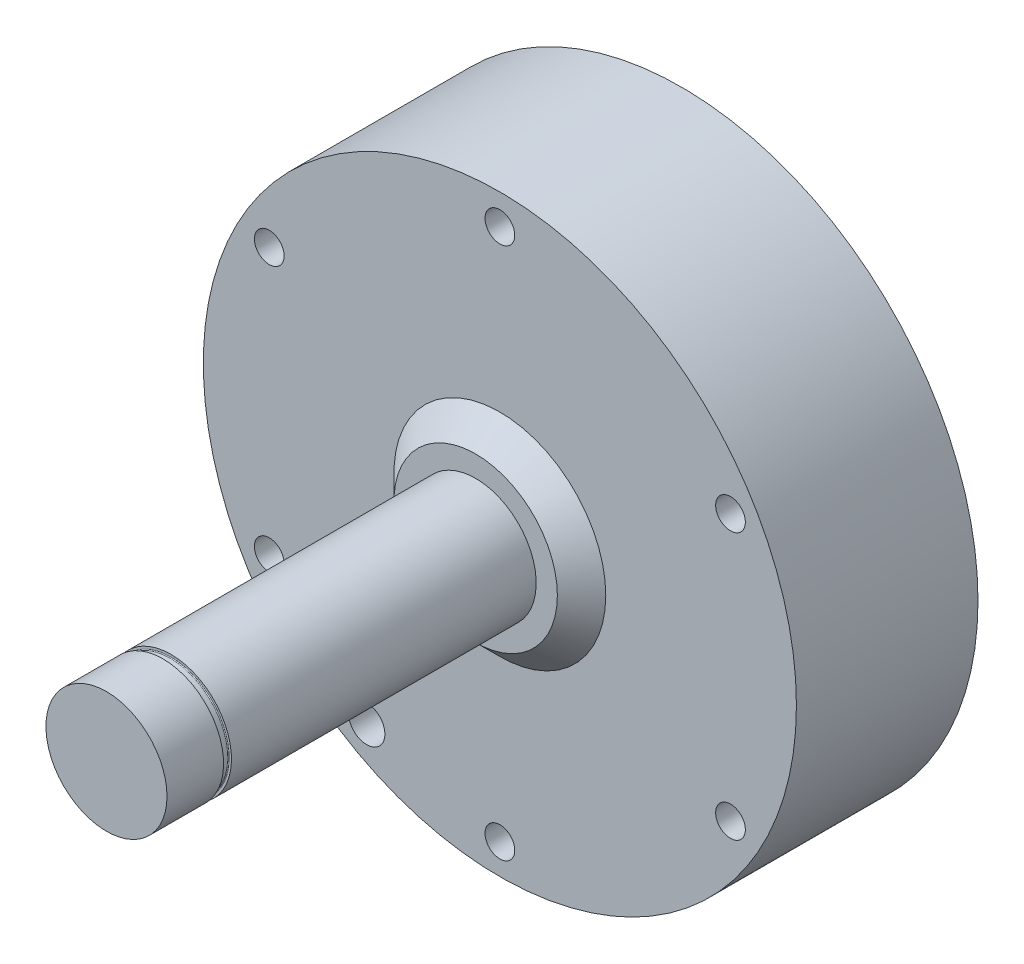
from build123d import *

# Parameters (mm, degrees)
ESQUISSE1_R                  = 49
BASE_EXTRUSION_DEPTH         = 30
ESQUISSE20_R                 = 3
ENL_V_MAT_EXTRU_4_DEPTH      = 12
ESQUISSE3_R                  = 10
BOSS_EXTRU_1_DEPTH           = 61
ESQUISSE11_R                 = 3
ENL_V_MAT_EXTRU_3_DEPTH      = 31.0000001
R_P_TITION_CIRCULAIRE1_COUNT = 6
R_P_TITION_CIRCULAIRE3_COUNT = 2
R_P_TITION_CIRCULAIRE3_ANGLE = 135
R_P_TITION_CIRCULAIRE4_COUNT = 3


with BuildPart() as part:
    # Esquisse1 → Base-Extrusion (new body)
    with BuildSketch(Plane.XY):
        Circle(ESQUISSE1_R)
    extrude(amount=BASE_EXTRUSION_DEPTH)

    # Esquisse2 → Boss.-Révol.1 (revolve)
    with BuildSketch(Plane(origin=(0, 0, 0), x_dir=(0, 0, -1), z_dir=(1, 0, 0))):
        Polygon((-30, 0), (-30, 17.5), (-34, 13.5), (-34, 0), align=None)
    revolve(axis=Axis((0, 0, 38.858858859), (0, 0, -1)))

    # Esquisse20 → Enlèv. mat.-Extru.4 (cut)
    with BuildSketch(Plane(origin=(-49, 0, 15), x_dir=(0, 1, 0), z_dir=(-1, 0, 0))):
        with Locations((0, -3)):
            Circle(ESQUISSE20_R)
    extrude(amount=-ENL_V_MAT_EXTRU_4_DEPTH, mode=Mode.SUBTRACT)

    # Esquisse3 → Boss.-Extru.1 (add)
    with BuildSketch(Plane.XY.offset(34)):
        Circle(ESQUISSE3_R)
    extrude(amount=BOSS_EXTRU_1_DEPTH)

    # Esquisse11 → Enlèv. mat.-Extru.3 (cut, through all)
    with BuildSketch(Plane.XY.offset(30)):
        with Locations((-22, -38.105117767)):
            Circle(ESQUISSE11_R)
    extrude(amount=-ENL_V_MAT_EXTRU_3_DEPTH, mode=Mode.SUBTRACT)

    # Esquisse12 → Perçage2 (revolve, cut)
    with BuildSketch(Plane(origin=(0, -44, 30), x_dir=(0, -1, 0), z_dir=(1, 0, 0))):
        Polygon((0, 0), (0, 26.47511282), (2.455, 25), (2.455, 0), align=None)
    per_age2 = revolve(axis=Axis((0, -44, 34.244199587), (0, 0, -1)), mode=Mode.SUBTRACT)

    # Répétition circulaire1: Perçage2 ×6 about axis
    r_p_tition_circulaire1_axis = Axis((0, 0, 0), (0, 0, 1))
    for i in range(1, R_P_TITION_CIRCULAIRE1_COUNT):
        add(per_age2.rotate(r_p_tition_circulaire1_axis, i * 360 / R_P_TITION_CIRCULAIRE1_COUNT), mode=Mode.SUBTRACT)

    # Esquisse16 → Perçage4 (revolve, cut)
    with BuildSketch(Plane(origin=(-21.242014496, 21.184353192, 0), x_dir=(0, 1, 0), z_dir=(1, 0, 0))):
        Polygon((0, 0), (0, 21.802581857), (3, 20), (3, 0), align=None)
    per_age4 = revolve(axis=Axis((-21.242014496, 21.184353192, -6.35), (0, 0, 1)), mode=Mode.SUBTRACT)

    # Répétition circulaire3: Perçage4 ×2 about axis
    r_p_tition_circulaire3_axis = Axis((0, 0, 0), (0, 0, -1))
    for i in range(1, R_P_TITION_CIRCULAIRE3_COUNT):
        add(per_age4.rotate(r_p_tition_circulaire3_axis, i * R_P_TITION_CIRCULAIRE3_ANGLE / (R_P_TITION_CIRCULAIRE3_COUNT - 1)), mode=Mode.SUBTRACT)

    # Esquisse18 → Perçage5 (revolve, cut)
    with BuildSketch(Plane(origin=(-30, -0.050785262, 0), x_dir=(0, 1, 0), z_dir=(1, 0, 0))):
        Polygon((0, 0), (0, 21.502151548), (2.5, 20), (2.5, 0), align=None)
    per_age5 = revolve(axis=Axis((-30, -0.050785262, -6.35), (0, 0, 1)), mode=Mode.SUBTRACT)

    # Répétition circulaire4: Perçage5 ×3 about axis
    r_p_tition_circulaire4_axis = Axis((0, 0, 0), (0, 0, 1))
    for i in range(1, R_P_TITION_CIRCULAIRE4_COUNT):
        add(per_age5.rotate(r_p_tition_circulaire4_axis, i * 360 / R_P_TITION_CIRCULAIRE4_COUNT), mode=Mode.SUBTRACT)

    # Groove Sketch → Retaining Ring Groove (revolve, cut)
    with BuildSketch(Plane(origin=(2.765923972, 3.631297113, 10.621036492), x_dir=(-0.506744947, -0.665289965, 0.548268931), z_dir=(0.795513937, -0.60593529, 0))):
        with BuildLine():
            Line((53.007122247, -54.964355603), (53.316554018, -54.761496098))
            Line((53.316554018, -54.761496098), (52.603804408, -53.674303387))
            Line((52.603804408, -53.674303387), (52.294372636, -53.877162891))
            ThreePointArc((52.294372636, -53.877162891), (52.238372455, -53.959405037), (52.256928326, -54.057157123))
            Line((52.256928326, -54.057157123), (52.827128014, -54.926911293))
            ThreePointArc((52.827128014, -54.926911293), (52.90937016, -54.982911474), (53.007122247, -54.964355603))
        make_face()
    revolve(axis=Axis((0, 0, 52.503783955), (0, 0, -1)), mode=Mode.SUBTRACT)


solid = part.part
